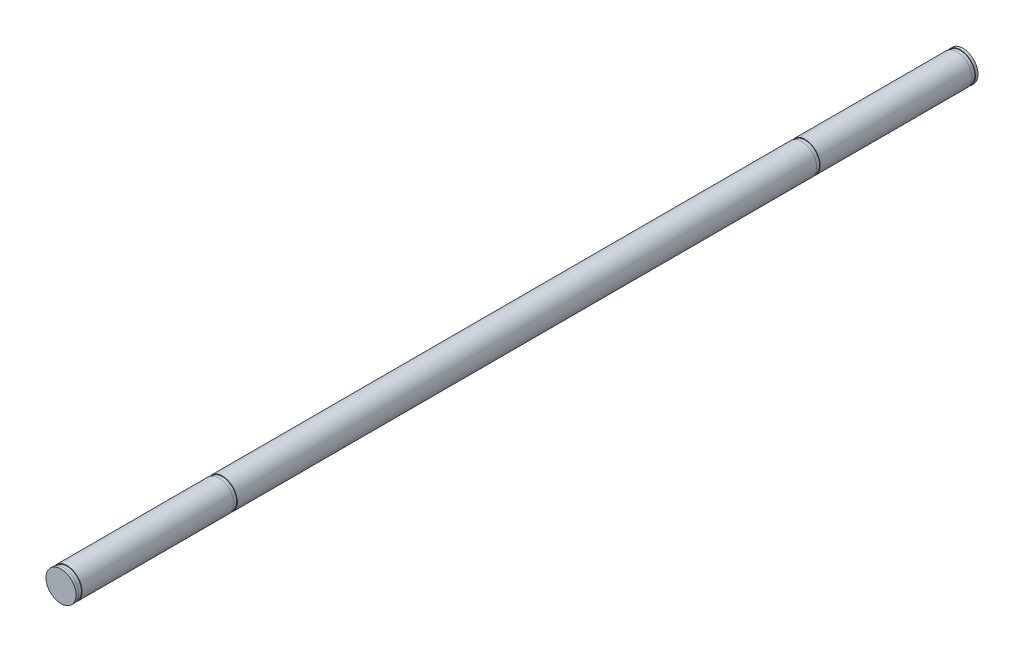
from build123d import *

# Parameters (mm, degrees)
SKETCH1_R           = 5
BOSS_EXTRUDE1_DEPTH = 150
SKETCH2_R           = 5
SKETCH2_R_2         = 4.8
CUT_EXTRUDE1_DEPTH  = 1.15
SKETCH3_R           = 5
SKETCH3_R_2         = 4.8
CUT_EXTRUDE2_DEPTH  = 1.15


with BuildPart() as part:
    # Sketch1 → Boss-Extrude1 (new, symmetric)
    with BuildSketch(Plane.XY):
        Circle(SKETCH1_R)
    extrude(amount=BOSS_EXTRUDE1_DEPTH, both=True)

    # Sketch2 → Cut-Extrude1 (cut)
    with BuildSketch(Plane.XY.offset(148)):
        Circle(SKETCH2_R)
        Circle(SKETCH2_R_2, mode=Mode.SUBTRACT)
    cut_extrude1 = extrude(amount=CUT_EXTRUDE1_DEPTH, mode=Mode.SUBTRACT)

    # Sketch3 → Cut-Extrude2 (cut)
    with BuildSketch(Plane.XY.offset(97.5)):
        Circle(SKETCH3_R)
        Circle(SKETCH3_R_2, mode=Mode.SUBTRACT)
    cut_extrude2 = extrude(amount=-CUT_EXTRUDE2_DEPTH, mode=Mode.SUBTRACT)

    # Mirror1: Cut-Extrude1, Cut-Extrude2 across plane
    add(cut_extrude1.mirror(Plane.XY), mode=Mode.SUBTRACT)
    add(cut_extrude2.mirror(Plane.XY), mode=Mode.SUBTRACT)


solid = part.part
